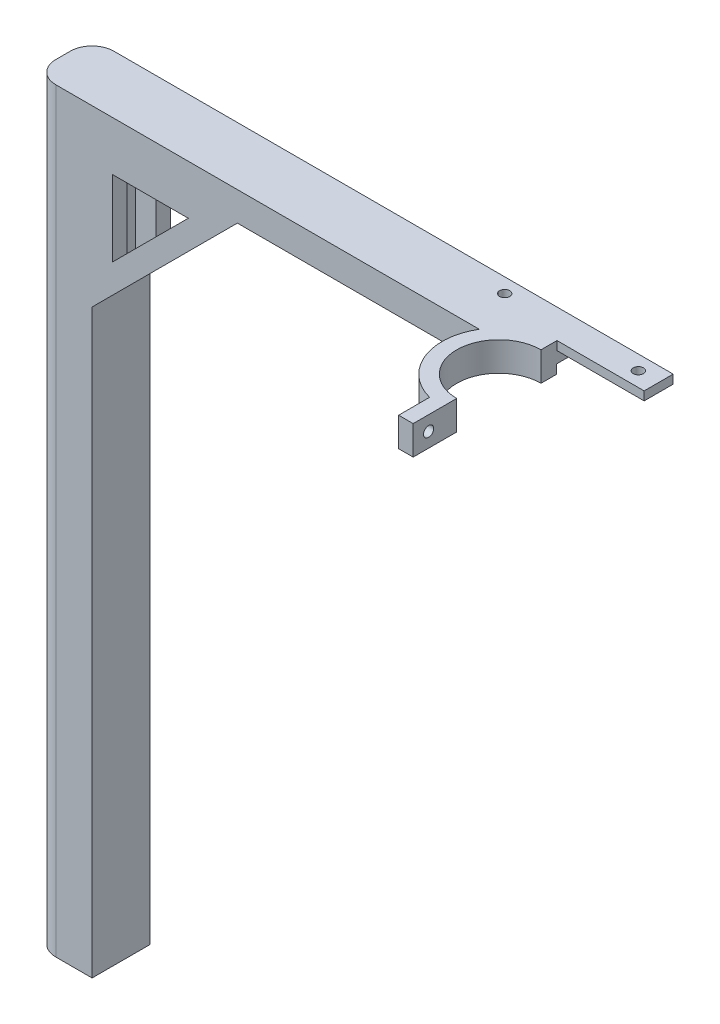
from build123d import *

# Parameters (mm, degrees)
SKETCH1_W           = 20
SKETCH1_H           = 20
BOSS_EXTRUDE1_DEPTH = 260
SKETCH2_W           = 20
SKETCH2_H           = 10
BOSS_EXTRUDE2_DEPTH = 150
BOSS_EXTRUDE3_DEPTH = 10
CUT_EXTRUDE1_DEPTH  = 261
SKETCH4_R           = 1.75
CUT_EXTRUDE2_DEPTH  = 6
BOSS_EXTRUDE4_DEPTH = 5
FILLET3_R           = 7.5
SKETCH7_R           = 2.5
CUT_EXTRUDE3_DEPTH  = 8
SKETCH9_W           = 10
SKETCH9_H           = 3
BOSS_EXTRUDE6_DEPTH = 30
SKETCH10_W          = 10.1
SKETCH10_H          = 3.1
CUT_EXTRUDE4_DEPTH  = 30.2
SKETCH11_R          = 1.75
CUT_EXTRUDE5_DEPTH  = 261


with BuildPart() as part:
    # Sketch1 → Boss-Extrude1 (new body)
    with BuildSketch(Plane(origin=(0, 0, 0), x_dir=(1, 0, 0), z_dir=(0, 1, 0))):
        with Locations((10, 10)):
            Rectangle(SKETCH1_W, SKETCH1_H)
    extrude(amount=BOSS_EXTRUDE1_DEPTH)

    # Sketch2 → Boss-Extrude2 (add)
    with BuildSketch(Plane(origin=(20, 0, 0), x_dir=(0, 0, -1), z_dir=(1, 0, 0))):
        with Locations((10, 255)):
            Rectangle(SKETCH2_W, SKETCH2_H)
    extrude(amount=BOSS_EXTRUDE2_DEPTH)

    # Sketch3 → Boss-Extrude3 (add)
    with BuildSketch(Plane(origin=(0, 260, 0), x_dir=(1, 0, 0), z_dir=(0, 1, 0))):
        with BuildLine():
            Line((159.5, 0), (153.259330957, 0))
            ThreePointArc((153.259330957, 0), (151.938520085, -17.350710392), (165, -28.848076825))
            Line((165, -28.848076825), (165, -24.5))
            Line((165, -24.5), (170, -24.5))
            ThreePointArc((170, -24.5), (156.672397065, -15.711829829), (159.5, 0))
        make_face()
        with BuildLine():
            Line((165, -24.5), (165, -28.848076825))
            ThreePointArc((165, -28.848076825), (167.478839363, -29.336332358), (170, -29.5))
            Line((170, -29.5), (170, -24.5))
            Line((170, -24.5), (165, -24.5))
        make_face()
        with BuildLine():
            ThreePointArc((170, -29.5), (167.478839363, -29.336332358), (165, -28.848076825))
            Line((165, -28.848076825), (165, -39.5))
            Line((165, -39.5), (170, -39.5))
            Line((170, -39.5), (170, -29.5))
        make_face()
    extrude(amount=-BOSS_EXTRUDE3_DEPTH)

    # Sketch3_3 → Cut-Extrude1 (cut, through all)
    with BuildSketch(Plane(origin=(0, 260, 0), x_dir=(1, 0, 0), z_dir=(0, 1, 0))):
        with BuildLine():
            Line((170, 0), (170, 4.5))
            ThreePointArc((170, 4.5), (164.288170171, 3.327602935), (159.5, 0))
            Line((159.5, 0), (170, 0))
        make_face()
    extrude(amount=-CUT_EXTRUDE1_DEPTH, mode=Mode.SUBTRACT)

    # Sketch4 → Cut-Extrude2 (cut, through all)
    with BuildSketch(Plane.ZY.offset(-165)):
        with Locations((34.174038412, 255)):
            Circle(SKETCH4_R)
    extrude(amount=-CUT_EXTRUDE2_DEPTH, mode=Mode.SUBTRACT)

    # Sketch5 → Boss-Extrude4 (add)
    with BuildSketch(Plane.XY):
        Polygon((70, 250), (20, 200), (20, 250), align=None)
        Polygon((53.100505063, 243), (27, 216.899494937), (27, 243), align=None, mode=Mode.SUBTRACT)
    boss_extrude4 = extrude(amount=-BOSS_EXTRUDE4_DEPTH)

    # Mirror1: Boss-Extrude4 across plane
    add(boss_extrude4.mirror(Plane.XY.offset(-10)))

    # Fillet3
    fillet3_edges = [part.edges().sort_by_distance(p)[0] for p in [
        (0, 130, -20),
        (0, 130, 0),
    ]]
    fillet(fillet3_edges, radius=FILLET3_R)

    # Sketch7 → Cut-Extrude3 (cut)
    with BuildSketch(Plane.XZ):
        with Locations((15, -5)):
            Circle(SKETCH7_R)
        with Locations((5, -10)):
            Circle(SKETCH7_R)
        with Locations((15, -15)):
            Circle(SKETCH7_R)
    extrude(amount=-CUT_EXTRUDE3_DEPTH, mode=Mode.SUBTRACT)

    # Sketch9 → Boss-Extrude6 (add)
    with BuildSketch(Plane(origin=(170, 0, 0), x_dir=(0, 0, -1), z_dir=(1, 0, 0))):
        with Locations((15, 258.5)):
            Rectangle(SKETCH9_W, SKETCH9_H)
    extrude(amount=BOSS_EXTRUDE6_DEPTH)

    # Sketch10 → Cut-Extrude4 (cut)
    with BuildSketch(Plane(origin=(170, 0, 0), x_dir=(0, 0, -1), z_dir=(1, 0, 0))):
        with Locations((14.95, 251.55)):
            Rectangle(SKETCH10_W, SKETCH10_H)
    extrude(amount=-CUT_EXTRUDE4_DEPTH, mode=Mode.SUBTRACT)

    # Sketch11 → Cut-Extrude5 (cut, through all)
    with BuildSketch(Plane(origin=(0, 260, 0), x_dir=(1, 0, 0), z_dir=(0, 1, 0))):
        with Locations((147, 15)):
            Circle(SKETCH11_R)
    cut_extrude5 = extrude(amount=-CUT_EXTRUDE5_DEPTH, mode=Mode.SUBTRACT)

    # Mirror2: Cut-Extrude5 across plane
    add(cut_extrude5.mirror(Plane(origin=(170, 0, 0), x_dir=(0, 0, 1), z_dir=(1, 0, 0))), mode=Mode.SUBTRACT)


solid = part.part
